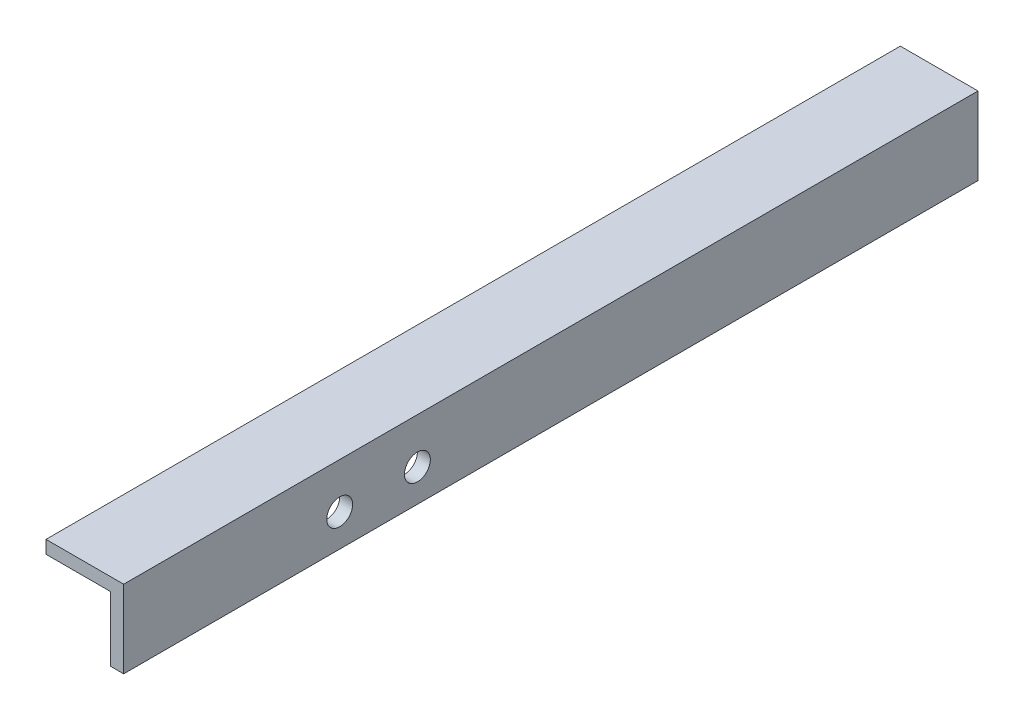
from build123d import *

# Parameters (mm, degrees)
EXTRUDE_THIN1_DEPTH      = 215.9
EXTRUDE_THIN1_DEPTH_BACK = 203.2
SKETCH2_R                = 6.35
CUT_EXTRUDE1_DEPTH       = 7.35


with BuildPart() as part:
    # Sketch1 → Extrude-Thin1 (new body, two sides)
    with BuildSketch(Plane.XY) as extrude_thin1_sk:
        Polygon((-269.875, 946.3), (-269.875, 984.4), (-307.975, 984.4), (-307.975, 978.05), (-276.225, 978.05), (-276.225, 946.3), align=None)
    extrude(amount=EXTRUDE_THIN1_DEPTH)
    extrude(extrude_thin1_sk.sketch, amount=-EXTRUDE_THIN1_DEPTH_BACK)

    # Sketch2 → Cut-Extrude1 (cut, through all)
    with BuildSketch(Plane.ZY.offset(276.225)):
        with Locations((109.908874461, 962.175)):
            Circle(SKETCH2_R)
        with Locations((71.808874461, 962.175)):
            Circle(SKETCH2_R)
    extrude(amount=-CUT_EXTRUDE1_DEPTH, mode=Mode.SUBTRACT)


solid = part.part
